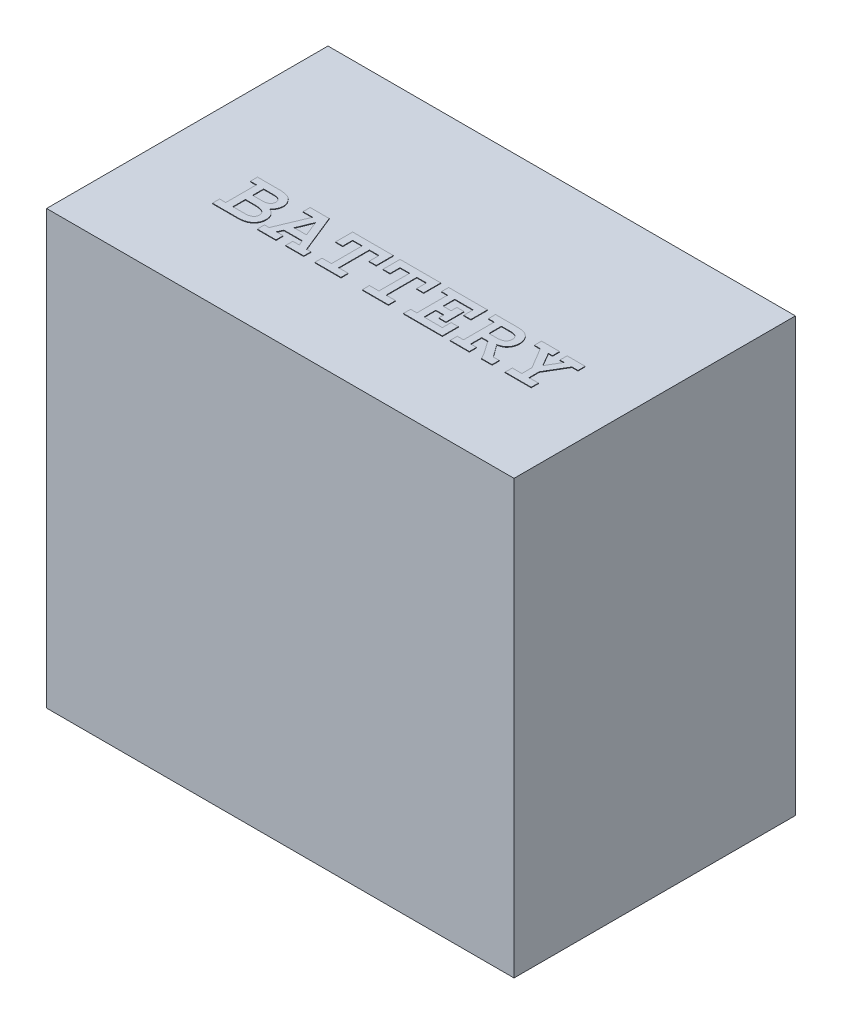
from build123d import *

# Parameters (mm, degrees)
SKETCH1_W           = 229.108
SKETCH1_H           = 212.09
BOSS_EXTRUDE1_DEPTH = 137.922
BOSS_EXTRUDE2_DEPTH = 0.254


with BuildPart() as part:
    # Sketch1 → Boss-Extrude1 (new body)
    with BuildSketch(Plane.XY):
        Rectangle(SKETCH1_W, SKETCH1_H)
    extrude(amount=BOSS_EXTRUDE1_DEPTH)

    # Sketch3 → Boss-Extrude2 (add)
    with BuildSketch(Plane(origin=(0, 106.045, 0), x_dir=(1, 0, 0), z_dir=(0, 1, 0))):
        with BuildLine():
            add(Edge.make_bspline(
                [(-55.795919174, -89.0469474), (-55.802432318, -88.820856628), (-55.815402663, -88.370617062), (-55.917726445, -87.702828656), (-56.092404213, -87.053818574), (-56.330221823, -86.427763555), (-56.639718478, -85.838689115), (-57.034385833, -85.308566998), (-57.510573921, -84.841973427), (-57.877159803, -84.588643788), (-58.063687427, -84.459743636)],
                knots=[0, 0, 0, 0, 0.000678078, 0.001350331, 0.002021004, 0.002691119, 0.003355812, 0.004010454, 0.004666143, 0.005345391, 0.005345391, 0.005345391, 0.005345391], degree=3))
            Line((-58.063687427, -84.459743636), (-59.434909838, -83.69680064))
            add(Edge.make_bspline(
                [(-59.434909838, -83.69680064), (-59.260997669, -83.548985516), (-58.918197688, -83.257625675), (-58.47322963, -82.762450339), (-58.087739739, -82.240520986), (-57.77548903, -81.686975534), (-57.529261366, -81.104920495), (-57.36708008, -80.491336652), (-57.253059646, -79.850210918), (-57.242429554, -79.410841288), (-57.237011297, -79.186890484)],
                knots=[0, 0, 0, 0, 0.000684056, 0.001348349, 0.001991863, 0.00262718, 0.003250625, 0.0038821, 0.004527647, 0.005198762, 0.005198762, 0.005198762, 0.005198762], degree=3))
            add(Edge.make_bspline(
                [(-57.237011297, -79.186890484), (-57.237447827, -79.011756266), (-57.238319154, -78.662182612), (-57.298516277, -78.140318901), (-57.425929377, -77.628982433), (-57.600067768, -77.124475323), (-57.823274543, -76.622585278), (-58.110788156, -76.133597868), (-58.4490396, -75.650044484), (-58.837525797, -75.174458478), (-59.291380669, -74.722093578), (-59.83891941, -74.337254014), (-60.456722709, -74.000497131), (-61.15638924, -73.721177711), (-61.936207262, -73.502622548), (-62.792517315, -73.327822653), (-63.730727781, -73.219701583), (-64.38266487, -73.187760614), (-64.721781661, -73.171145945)],
                knots=[0, 0, 0, 0, 0.00052517, 0.001048256, 0.001571194, 0.002102888, 0.002647911, 0.003216029, 0.003801751, 0.004416807, 0.005056699, 0.005717059, 0.006416938, 0.007163746, 0.00797166, 0.00884363, 0.009783099, 0.010801542, 0.010801542, 0.010801542, 0.010801542], degree=3))
            Line((-64.721781661, -73.171145945), (-75.921821716, -73.16556575))
            Line((-75.921821716, -73.16556575), (-75.921821716, -76.695701705))
            Line((-75.921821716, -76.695701705), (-72.91034932, -76.695701705))
            Line((-72.91034932, -76.695701705), (-72.91034932, -91.754601917))
            Line((-72.91034932, -91.754601917), (-75.921821716, -91.754601917))
            Line((-75.921821716, -91.754601917), (-75.921821716, -95.284732417))
            Line((-75.921821716, -95.284732417), (-63.252717653, -95.284732417))
            add(Edge.make_bspline(
                [(-63.252717653, -95.284732417), (-62.956466815, -95.27353041), (-62.37928819, -95.2517058), (-61.542321951, -95.158663835), (-60.762094957, -95.007070834), (-60.035810095, -94.807564491), (-59.365739591, -94.551887588), (-58.749352719, -94.242199993), (-58.189353059, -93.880796377), (-57.691289549, -93.46371531), (-57.248344833, -93.010250017), (-56.863102739, -92.525130893), (-56.536085134, -92.011941826), (-56.265581871, -91.473956165), (-56.057532892, -90.90605386), (-55.914972323, -90.311570378), (-55.821784041, -89.690804229), (-55.808359308, -89.267468818), (-55.801499369, -89.051147546)],
                knots=[0, 0, 0, 0, 0.000889204, 0.001732415, 0.002523332, 0.003271413, 0.00398925, 0.004671203, 0.005337395, 0.005983909, 0.006615902, 0.007236136, 0.007838894, 0.008438409, 0.009039223, 0.009648853, 0.01026974, 0.010918542, 0.010918542, 0.010918542, 0.010918542], degree=3))
            Line((-55.801499369, -89.051147546), (-55.795919174, -89.0469474))
        make_face()
        with BuildLine():
            add(Edge.make_bspline(
                [(-60.747602933, -79.300583544), (-60.763364048, -79.445816231), (-60.793664294, -79.725021505), (-60.898275987, -80.118503204), (-61.029642261, -80.47523258), (-61.20471514, -80.791455665), (-61.416802469, -81.069665502), (-61.675793014, -81.300350364), (-61.965993443, -81.500518573), (-62.397357027, -81.685794817), (-62.921380204, -81.858316413), (-63.497509072, -82.020294185), (-64.000266711, -82.109603741), (-64.308192025, -82.104787563), (-64.448084834, -82.102599537)],
                knots=[0, 0, 0, 0, 0.000437647, 0.000841362, 0.001217928, 0.001575453, 0.001921808, 0.002261845, 0.002611964, 0.002974386, 0.003665044, 0.004266637, 0.004769873, 0.005188834, 0.005188834, 0.005188834, 0.005188834], degree=3))
            Line((-64.448084834, -82.102599537), (-69.380213366, -82.102599537))
            Line((-69.380213366, -82.102599537), (-69.380213366, -76.695701705))
            Line((-69.380213366, -76.695701705), (-64.254698084, -76.695701705))
            add(Edge.make_bspline(
                [(-64.254698084, -76.695701705), (-64.099318954, -76.703148463), (-63.799728313, -76.717506755), (-63.368114619, -76.768326307), (-62.972069027, -76.839035578), (-62.611276918, -76.933874199), (-62.285914341, -77.051275872), (-61.992320148, -77.187995969), (-61.738597088, -77.358357967), (-61.454504833, -77.607032687), (-61.171786142, -77.949434297), (-60.918429924, -78.381741128), (-60.767633582, -78.838167648), (-60.756144414, -79.148578786), (-60.750384848, -79.304189124)],
                knots=[0, 0, 0, 0, 0.000466556, 0.000899579, 0.001302753, 0.001672631, 0.00201718, 0.002339458, 0.002641548, 0.002930548, 0.003469787, 0.00396515, 0.004427984, 0.004893239, 0.004893239, 0.004893239, 0.004893239], degree=3))
            Line((-60.750384848, -79.304189124), (-60.747602933, -79.300583544))
        make_face(mode=Mode.SUBTRACT)
        with BuildLine():
            add(Edge.make_bspline(
                [(-59.326055129, -88.811499181), (-59.340053338, -88.953204176), (-59.366983138, -89.225816706), (-59.450605793, -89.616007263), (-59.572750393, -89.968808215), (-59.731237389, -90.285515611), (-59.920018952, -90.569853442), (-60.154156011, -90.81075886), (-60.419295407, -91.022338099), (-60.816710909, -91.241187532), (-61.315915097, -91.455331863), (-61.900712763, -91.635540444), (-62.445326887, -91.755082336), (-62.799783306, -91.754756464), (-62.96788771, -91.754601917)],
                knots=[0, 0, 0, 0, 0.000426943, 0.000821355, 0.00119409, 0.001543807, 0.001881543, 0.002213407, 0.002547521, 0.002895314, 0.003570808, 0.004173256, 0.004730843, 0.005233831, 0.005233831, 0.005233831, 0.005233831], degree=3))
            Line((-62.96788771, -91.754601917), (-69.380213366, -91.754601917))
            Line((-69.380213366, -91.754601917), (-69.380213366, -85.632735491))
            Line((-69.380213366, -85.632735491), (-64.998620416, -85.632735491))
            add(Edge.make_bspline(
                [(-64.998620416, -85.632735491), (-64.766622255, -85.626856299), (-64.26750782, -85.614207967), (-63.468790759, -85.683340439), (-62.573679259, -85.820721631), (-61.780559827, -85.985491448), (-61.137091937, -86.168198751), (-60.697838089, -86.37760711), (-60.321050177, -86.647586979), (-60.000923549, -86.972199272), (-59.741797012, -87.353016893), (-59.538078367, -87.78977411), (-59.400539527, -88.284754739), (-59.355132179, -88.635176223), (-59.331629869, -88.816550266)],
                knots=[0, 0, 0, 0, 0.000695785, 0.001496892, 0.002400595, 0.003411782, 0.003925935, 0.004403108, 0.004863475, 0.005309803, 0.005763755, 0.006238536, 0.006749523, 0.007297771, 0.007297771, 0.007297771, 0.007297771], degree=3))
            Line((-59.331629869, -88.816550266), (-59.326055129, -88.811499181))
        make_face(mode=Mode.SUBTRACT)
        Polygon((-31.129690869, -95.284732417), (-31.129690869, -91.754601917), (-33.266523642, -91.754601917), (-40.763556252, -73.16556575), (-50.111075277, -73.16556575), (-50.111075277, -76.695701705), (-45.362214961, -76.695701705), (-51.655420095, -91.754601917), (-53.933328701, -91.754601917), (-53.933328701, -95.284732417), (-44.744477034, -95.284732417), (-44.744477034, -91.754601917), (-48.064818393, -91.754601917), (-46.9451684, -89.207551188), (-37.961038424, -89.207551188), (-36.854201605, -91.754601917), (-40.022044914, -91.754601917), (-40.022044914, -95.284732417), align=None)
        Polygon((-39.373209537, -85.677415233), (-45.439432202, -85.677415233), (-42.402758927, -78.292630177), align=None, mode=Mode.SUBTRACT)
        Polygon((-9.323315121, -81.57239921), (-9.323315121, -73.16556575), (-29.297597825, -73.16556575), (-29.297597825, -81.57239921), (-25.76746187, -81.57239921), (-25.76746187, -76.695701705), (-21.075521723, -76.695701705), (-21.075521723, -91.754601917), (-25.690550094, -91.754601917), (-25.690550094, -95.284732417), (-12.892223338, -95.284732417), (-12.892223338, -91.754601917), (-17.545385768, -91.754601917), (-17.545385768, -76.695701705), (-12.853451076, -76.695701705), (-12.853451076, -81.57239921), align=None)
        Polygon((13.912986906, -81.57239921), (13.912986906, -73.16556575), (-6.061295798, -73.16556575), (-6.061295798, -81.57239921), (-2.531159843, -81.57239921), (-2.531159843, -76.695701705), (2.160780304, -76.695701705), (2.160780304, -91.754601917), (-2.454248067, -91.754601917), (-2.454248067, -95.284732417), (10.344078688, -95.284732417), (10.344078688, -91.754601917), (5.690916259, -91.754601917), (5.690916259, -76.695701705), (10.382850951, -76.695701705), (10.382850951, -81.57239921), align=None)
        Polygon((36.791807362, -95.284732417), (36.791807362, -87.464823081), (33.261671408, -87.464823081), (33.261671408, -91.754601917), (24.27995788, -91.754601917), (24.27995788, -85.990217061), (28.256934887, -85.990217061), (28.256934887, -88.492588049), (31.787065387, -88.492588049), (31.787065387, -79.633742446), (28.256934887, -79.633742446), (28.256934887, -82.460081106), (24.27995788, -82.460081106), (24.27995788, -76.695701705), (33.261671408, -76.695701705), (33.261671408, -81.309442759), (36.791807362, -81.309442759), (36.791807362, -73.16556575), (17.77695815, -73.16556575), (17.77695815, -76.695701705), (20.749821925, -76.695701705), (20.749821925, -91.754601917), (17.699740909, -91.754601917), (17.699740909, -95.284732417), align=None)
        with BuildLine():
            Line((61.147983026, -95.284732417), (61.147983026, -91.754601917))
            Line((61.147983026, -91.754601917), (58.252336492, -91.754601917))
            Line((58.252336492, -91.754601917), (53.801893867, -85.664427507))
            Line((53.801893867, -85.664427507), (55.316990391, -85.208913424))
            add(Edge.make_bspline(
                [(55.316990391, -85.208913424), (55.568206317, -85.115805098), (56.072491195, -84.928901659), (56.751976253, -84.470958732), (57.371959808, -83.899264651), (57.905771656, -83.198614949), (58.36058291, -82.4078293), (58.682092298, -81.526940862), (58.897697591, -80.580443633), (58.928621038, -79.921704493), (58.944498836, -79.5834716)],
                knots=[0, 0, 0, 0, 0.00080125, 0.00160841, 0.002438438, 0.003322208, 0.004240193, 0.005164597, 0.006125475, 0.007139497, 0.007139497, 0.007139497, 0.007139497], degree=3))
            add(Edge.make_bspline(
                [(58.944498836, -79.5834716), (58.937256314, -79.299750949), (58.922957479, -78.739604201), (58.768694485, -77.91942392), (58.537289389, -77.129468719), (58.200248403, -76.380259877), (57.771564381, -75.681299206), (57.247532617, -75.044627812), (56.615199255, -74.493765986), (56.137432343, -74.194519715), (55.894734195, -74.042507271)],
                knots=[0, 0, 0, 0, 0.000850194, 0.001678529, 0.002494951, 0.003315034, 0.004135079, 0.004948228, 0.005779496, 0.006637743, 0.006637743, 0.006637743, 0.006637743], degree=3))
            add(Edge.make_bspline(
                [(55.894734195, -74.042507271), (55.721196075, -73.955400965), (55.371668531, -73.779957938), (54.818941889, -73.576900834), (54.245711253, -73.417095653), (53.452561904, -73.283593776), (52.44746516, -73.180017011), (51.638747763, -73.174093624), (51.23630249, -73.171145945)],
                knots=[0, 0, 0, 0, 0.000582115, 0.001172452, 0.001763265, 0.00236478, 0.003583079, 0.004789903, 0.004789903, 0.004789903, 0.004789903], degree=3))
            Line((51.23630249, -73.171145945), (40.732995848, -73.16556575))
            Line((40.732995848, -73.16556575), (40.732995848, -76.695701705))
            Line((40.732995848, -76.695701705), (43.628642382, -76.695701705))
            Line((43.628642382, -76.695701705), (43.628642382, -91.754601917))
            Line((43.628642382, -91.754601917), (40.578561366, -91.754601917))
            Line((40.578561366, -91.754601917), (40.578561366, -95.284732417))
            Line((40.578561366, -95.284732417), (50.03357687, -95.284732417))
            Line((50.03357687, -95.284732417), (50.03357687, -91.754601917))
            Line((50.03357687, -91.754601917), (47.158778337, -91.754601917))
            Line((47.158778337, -91.754601917), (47.158778337, -86.347698631))
            Line((47.158778337, -86.347698631), (50.150122757, -86.347698631))
            Line((50.150122757, -86.347698631), (53.568802094, -91.270417742))
            add(Edge.make_bspline(
                [(53.568802094, -91.270417742), (53.801687945, -91.599148201), (54.262449662, -92.249537264), (54.891807116, -93.250807656), (55.46676484, -94.257876623), (55.805022838, -94.944095186), (55.972933288, -95.284732417)],
                knots=[0, 0, 0, 0, 0.001208387, 0.002390778, 0.0035464, 0.004685489, 0.004685489, 0.004685489, 0.004685489], degree=3))
            Line((55.972933288, -95.284732417), (61.147983026, -95.284732417))
        make_face()
        with BuildLine():
            add(Edge.make_bspline(
                [(55.433907199, -79.621649297), (55.418552204, -79.797566437), (55.389240217, -80.133384256), (55.280998141, -80.607864008), (55.131634321, -81.031227186), (54.935451396, -81.405095766), (54.69251503, -81.728000046), (54.404603069, -82.002587347), (54.062830619, -82.215973175), (53.556991246, -82.422850057), (52.90374512, -82.59786007), (52.134556905, -82.762101543), (51.382976999, -82.839038736), (50.891944881, -82.824655348), (50.64980929, -82.817562676)],
                knots=[0, 0, 0, 0, 0.000529231, 0.001010279, 0.001455522, 0.001872804, 0.002271621, 0.002662816, 0.003059515, 0.003472438, 0.004298, 0.005084526, 0.005830958, 0.006557113, 0.006557113, 0.006557113, 0.006557113], degree=3))
            Line((50.64980929, -82.817562676), (47.158778337, -82.817562676))
            Line((47.158778337, -82.817562676), (47.158778337, -76.695701705))
            Line((47.158778337, -76.695701705), (51.976008312, -76.695701705))
            add(Edge.make_bspline(
                [(51.976008312, -76.695701705), (52.12621749, -76.691449886), (52.443852941, -76.682458899), (52.945390537, -76.758880877), (53.495544469, -76.894679583), (53.976346185, -77.060794697), (54.36458723, -77.245496597), (54.628317673, -77.440805493), (54.849853128, -77.691193319), (55.043083161, -77.982617174), (55.188094772, -78.32945918), (55.316718631, -78.716062596), (55.387817381, -79.155162199), (55.416275836, -79.462305598), (55.431125284, -79.622571147)],
                knots=[0, 0, 0, 0, 0.000450038, 0.000951659, 0.001515228, 0.002149464, 0.002474201, 0.002801522, 0.003125779, 0.003472809, 0.003845418, 0.004249944, 0.004692587, 0.005175576, 0.005175576, 0.005175576, 0.005175576], degree=3))
            Line((55.431125284, -79.622571147), (55.433907199, -79.621649297))
        make_face(mode=Mode.SUBTRACT)
        Polygon((84.688152024, -76.695701705), (84.688152024, -73.16556575), (75.80816932, -73.16556575), (75.80816932, -76.695701705), (77.893034824, -76.695701705), (74.010926583, -83.28893913), (70.168654277, -76.695701705), (72.176302541, -76.695701705), (72.176302541, -73.16556575), (63.296319837, -73.16556575), (63.296319837, -76.695701705), (66.191966371, -76.695701705), (72.227167953, -86.761031241), (72.227167953, -91.754601917), (67.555524878, -91.754601917), (67.555524878, -95.284732417), (80.351729742, -95.284732417), (80.351729742, -91.754601917), (75.757303908, -91.754601917), (75.757303908, -86.761031241), (81.715288249, -76.695701705), align=None)
    extrude(amount=BOSS_EXTRUDE2_DEPTH)


solid = part.part
